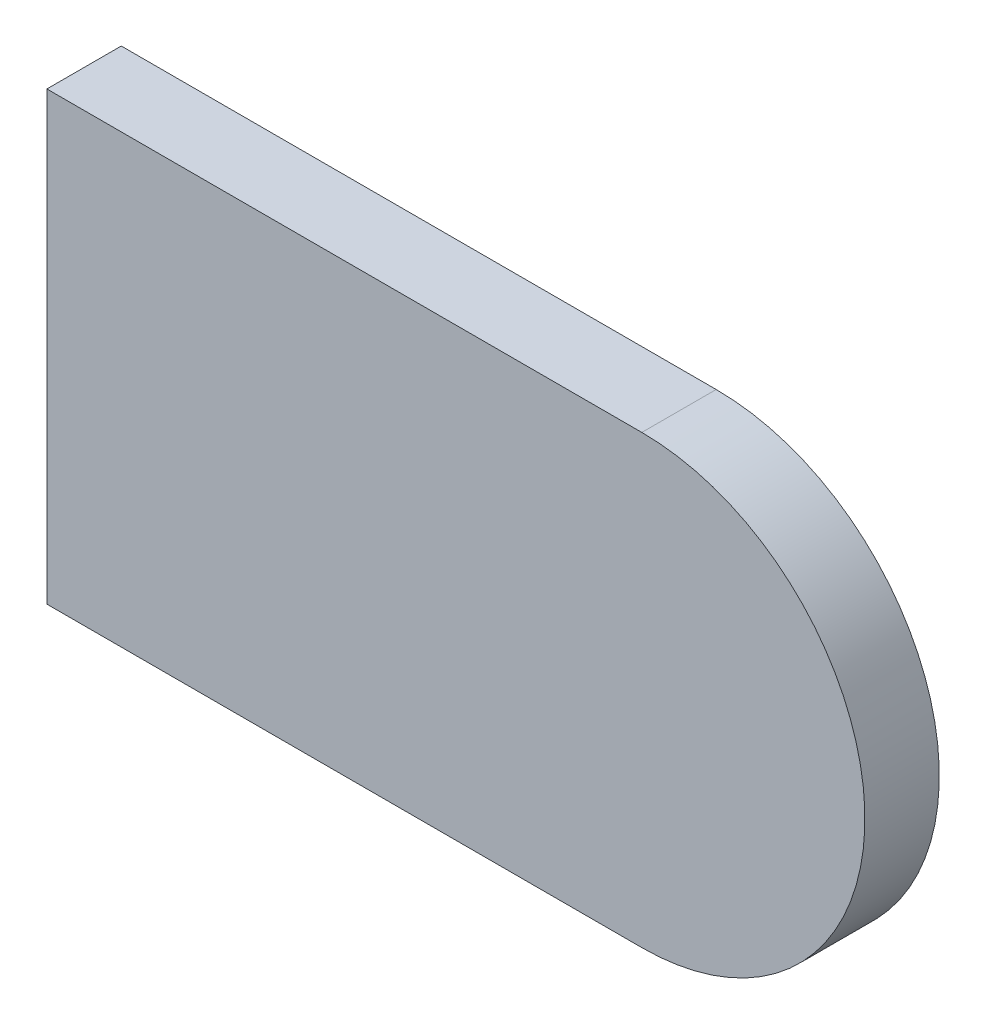
from build123d import *

# Parameters (mm, degrees)
BOSS_EXTRUDE1_DEPTH = 10


with BuildPart() as part:
    # Sketch1 → Boss-Extrude1 (new body)
    with BuildSketch(Plane.XY):
        with BuildLine():
            Line((0, 0), (80, 0))
            ThreePointArc((80, 0), (110, -30), (80, -60))
            Line((80, -60), (0, -60))
            Line((0, -60), (0, 0))
        make_face()
    extrude(amount=BOSS_EXTRUDE1_DEPTH)


solid = part.part
